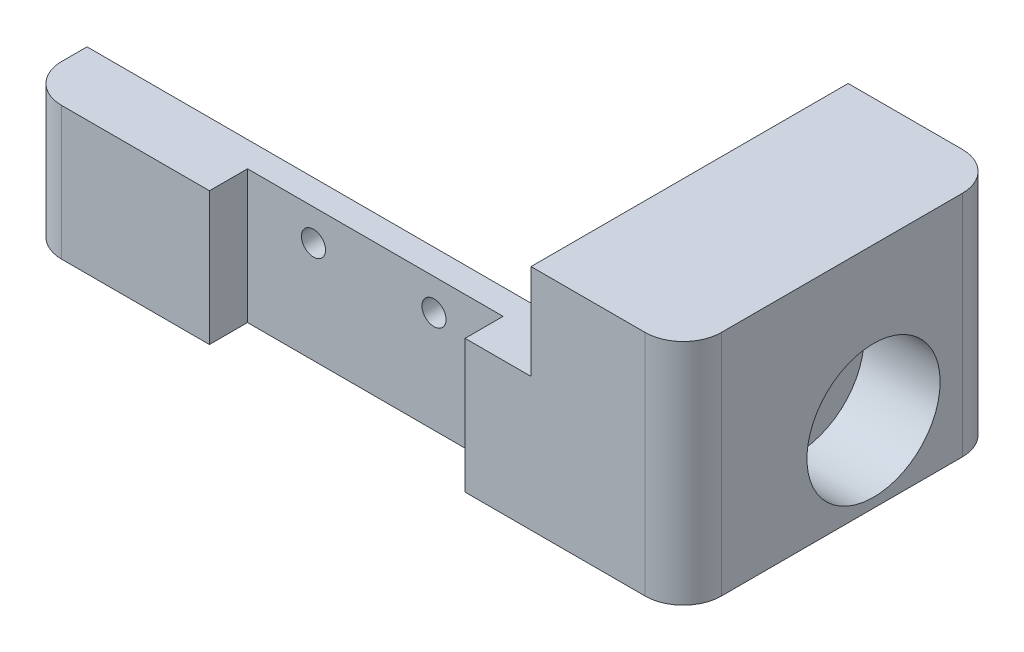
from build123d import *

# Parameters (mm, degrees)
SKETCH1_W                      = 40
SKETCH1_H                      = 10.5
BOSS_EXTRUDE1_DEPTH            = 2
SKETCH2_W                      = 14.65
SKETCH2_H                      = 10.5
SKETCH2_W_2                    = 5.2
BOSS_EXTRUDE2_DEPTH            = 3
SKETCH3_W                      = 25
SKETCH3_H                      = 18
BOSS_EXTRUDE3_DEPTH            = 12
CBORE_FOR_M5_SHCS1_D           = 5.5
CBORE_FOR_M5_SHCS1_DEPTH       = 12
CBORE_FOR_M5_SHCS1_CBORE_D     = 10.5
CBORE_FOR_M5_SHCS1_CBORE_DEPTH = 6
FILLET1_R                      = 3
SKETCH6_R                      = 0.95
CUT_EXTRUDE1_DEPTH             = 23


with BuildPart() as part:
    # Sketch1 → Boss-Extrude1 (new body)
    with BuildSketch(Plane.XY):
        with Locations((-20, 5.25)):
            Rectangle(SKETCH1_W, SKETCH1_H)
    extrude(amount=BOSS_EXTRUDE1_DEPTH)

    # Sketch2 → Boss-Extrude2 (add)
    with BuildSketch(Plane.XY.offset(2)):
        with Locations((-32.675, 5.25)):
            Rectangle(SKETCH2_W, SKETCH2_H)
        with Locations((-2.6, 5.25)):
            Rectangle(SKETCH2_W_2, SKETCH2_H)
    extrude(amount=BOSS_EXTRUDE2_DEPTH)

    # Sketch3 → Boss-Extrude3 (add)
    with BuildSketch(Plane(origin=(0, 0, 0), x_dir=(0, 0, -1), z_dir=(1, 0, 0))):
        with Locations((7.5, 9)):
            Rectangle(SKETCH3_W, SKETCH3_H)
    extrude(amount=BOSS_EXTRUDE3_DEPTH)

    # CBORE for M5 SHCS1
    with Locations(Plane(origin=(12, 0, 0), x_dir=(0, 0, -1), z_dir=(1, 0, 0))):
        with Locations((10, 6)):
            CounterBoreHole(CBORE_FOR_M5_SHCS1_D / 2, CBORE_FOR_M5_SHCS1_CBORE_D / 2, CBORE_FOR_M5_SHCS1_CBORE_DEPTH, depth=CBORE_FOR_M5_SHCS1_DEPTH)

    # Fillet1
    fillet1_edges = [part.edges().sort_by_distance(p)[0] for p in [
        (-40, 5.25, 5),
        (12, 9, 5),
        (12, 9, -20),
    ]]
    fillet(fillet1_edges, radius=FILLET1_R)

    # Sketch6 → Cut-Extrude1 (cut, through all)
    with BuildSketch(Plane.XY.offset(2)):
        with Locations((-20.15, 8.022701753)):
            Circle(SKETCH6_R)
        with Locations((-10.65, 8.022701753)):
            Circle(SKETCH6_R)
    extrude(amount=-CUT_EXTRUDE1_DEPTH, mode=Mode.SUBTRACT)


solid = part.part
